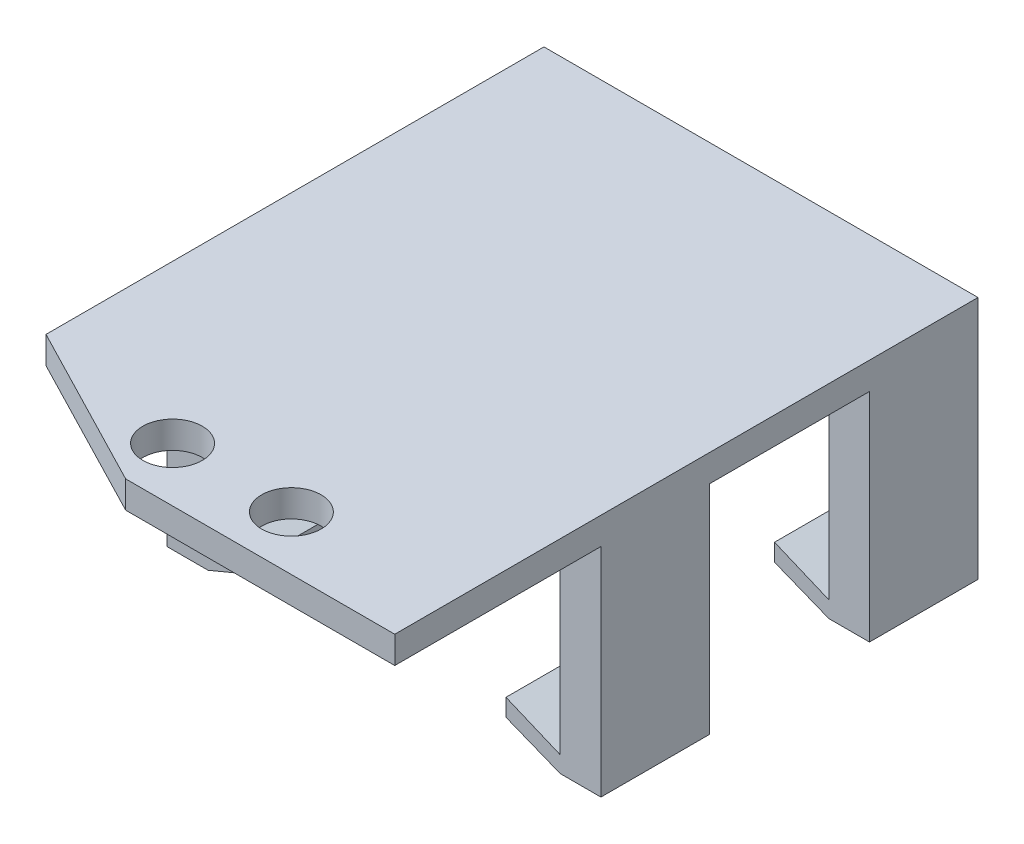
from build123d import *

# Parameters (mm, degrees)
SKETCH3_R           = 2.7813
BOSS_EXTRUDE3_DEPTH = 2.54
SKETCH4_W           = 3.81
SKETCH4_H           = 40.386
BOSS_EXTRUDE4_DEPTH = 20.32
SKETCH5_W           = 40.386
SKETCH5_H           = 1.524
BOSS_EXTRUDE5_DEPTH = 5.08
SKETCH6_W           = 40.386
SKETCH6_H           = 1.524
BOSS_EXTRUDE6_DEPTH = 5.08
SKETCH7_W           = 40.64
SKETCH7_H           = 20.32
CUT_EXTRUDE1_DEPTH  = 5.08
SKETCH11_W          = 40.64
SKETCH11_H          = 35.306
BOSS_EXTRUDE7_DEPTH = 2.9718
BOSS_EXTRUDE8_DEPTH = 35.306
SKETCH8_W           = 14.986
SKETCH8_H           = 20.32
CUT_EXTRUDE2_DEPTH  = 41.64
CUT_EXTRUDE3_DEPTH  = 36.306
SKETCH14_R          = 3.81
SKETCH14_R_2        = 2.7813
BOSS_EXTRUDE9_DEPTH = 2.54
CUT_EXTRUDE4_DEPTH  = 23.86


with BuildPart() as part:
    # Sketch3 → Boss-Extrude3 (new body)
    with BuildSketch(Plane(origin=(0, 0, 0), x_dir=(1, 0, 0), z_dir=(0, 1, 0))):
        Polygon((-11.517251908, 12.440983784), (29.122748092, 12.440983784), (29.122748092, -34.564151764), (29.122748092, -42.169016216), (18.885256114, -42.169016216), (-11.517251908, -42.169016216), align=None)
        with Locations((3.240148092, -37.089016216)):
            Circle(SKETCH3_R, mode=Mode.SUBTRACT)
        with Locations((14.365348092, -37.089016216)):
            Circle(SKETCH3_R, mode=Mode.SUBTRACT)
    extrude(amount=BOSS_EXTRUDE3_DEPTH)

    # Sketch4 → Boss-Extrude4 (add)
    with BuildSketch(Plane.XZ):
        with Locations((-9.612251908, 7.752016216)):
            Rectangle(SKETCH4_W, SKETCH4_H)
        with Locations((27.217748092, 7.752016216)):
            Rectangle(SKETCH4_W, SKETCH4_H)
    extrude(amount=BOSS_EXTRUDE4_DEPTH)

    # Sketch5 → Boss-Extrude5 (add)
    with BuildSketch(Plane(origin=(-7.707251908, 0, 0), x_dir=(0, 0, -1), z_dir=(1, 0, 0))):
        with Locations((-7.752016216, -19.558)):
            Rectangle(SKETCH5_W, SKETCH5_H)
    extrude(amount=BOSS_EXTRUDE5_DEPTH)

    # Sketch6 → Boss-Extrude6 (add)
    with BuildSketch(Plane.ZY.offset(-25.312748092)):
        with Locations((7.752016216, -19.558)):
            Rectangle(SKETCH6_W, SKETCH6_H)
    extrude(amount=BOSS_EXTRUDE6_DEPTH)

    # Sketch7 → Cut-Extrude1 (cut)
    with BuildSketch(Plane.XY.offset(27.945016216)):
        with Locations((8.802748092, -10.16)):
            Rectangle(SKETCH7_W, SKETCH7_H)
    extrude(amount=-CUT_EXTRUDE1_DEPTH, mode=Mode.SUBTRACT)

    # Sketch11 → Boss-Extrude7 (add)
    with BuildSketch(Plane.XZ):
        with Locations((8.802748092, 5.212016216)):
            Rectangle(SKETCH11_W, SKETCH11_H)
    extrude(amount=BOSS_EXTRUDE7_DEPTH)

    # Sketch12 → Boss-Extrude8 (add)
    with BuildSketch(Plane.XY.offset(22.865016216)):
        Polygon((-7.707251908, -18.796), (-2.593407451, -16.66881978), (-2.627251908, -18.796), align=None)
        Polygon((20.232748092, -18.796), (20.232748092, -16.66881978), (25.312748092, -18.796), align=None)
    extrude(amount=-BOSS_EXTRUDE8_DEPTH)

    # Sketch8 → Cut-Extrude2 (cut, through all)
    with BuildSketch(Plane(origin=(29.122748092, 0, 0), x_dir=(0, 0, -1), z_dir=(1, 0, 0))):
        with Locations((-5.212016216, -10.16)):
            Rectangle(SKETCH8_W, SKETCH8_H)
    extrude(amount=-CUT_EXTRUDE2_DEPTH, mode=Mode.SUBTRACT)

    # Sketch13 → Cut-Extrude3 (cut, through all)
    with BuildSketch(Plane.XY.offset(22.865016216)):
        Polygon((-2.618031664, -18.216492377), (-7.660745747, -20.32), (-2.627251908, -20.32), (-2.627251908, -18.796), align=None)
        Polygon((20.232748092, -18.294602636), (20.232748092, -20.32), (25.312748092, -20.32), align=None)
    extrude(amount=-CUT_EXTRUDE3_DEPTH, mode=Mode.SUBTRACT)

    # Sketch14 → Boss-Extrude9 (add)
    with BuildSketch(Plane.XZ):
        with Locations((3.240148092, 37.089016216)):
            Circle(SKETCH14_R)
        with Locations((3.240148092, 37.089016216)):
            Circle(SKETCH14_R_2, mode=Mode.SUBTRACT)
        with Locations((14.365348092, 37.089016216)):
            Circle(SKETCH14_R)
        with Locations((14.365348092, 37.089016216)):
            Circle(SKETCH14_R_2, mode=Mode.SUBTRACT)
    extrude(amount=-BOSS_EXTRUDE9_DEPTH)

    # Sketch15 → Cut-Extrude4 (cut, through all)
    with BuildSketch(Plane(origin=(0, 2.54, 0), x_dir=(1, 0, 0), z_dir=(0, 1, 0))):
        Polygon((-11.517251908, -42.169016216), (3.92724007, -42.169016216), (-11.517251908, -34.183083779), align=None)
    extrude(amount=-CUT_EXTRUDE4_DEPTH, mode=Mode.SUBTRACT)


solid = part.part
